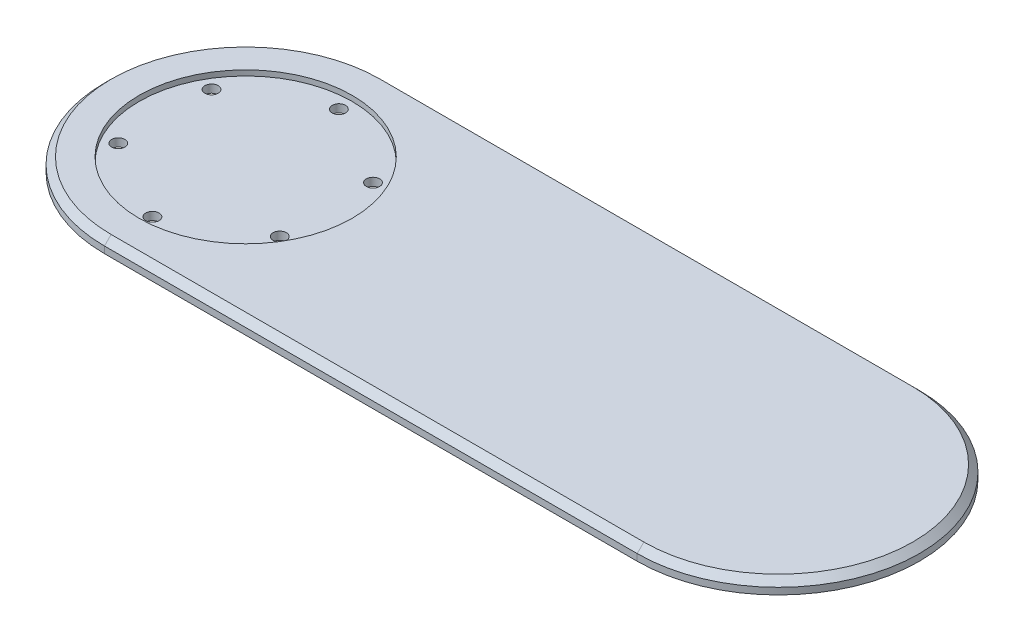
from build123d import *

# Parameters (mm, degrees)
SKETCH1_R           = 2.5
BOSS_EXTRUDE1_DEPTH = 5
SKETCH2_R           = 40
CUT_EXTRUDE1_DEPTH  = 2
CHAMFER1_SIZE       = 2.5


with BuildPart() as part:
    # Sketch1 → Boss-Extrude1 (new body)
    with BuildSketch(Plane(origin=(0, 0, 0), x_dir=(1, 0, 0), z_dir=(0, 1, 0))):
        with BuildLine():
            Line((-100, -53), (100, -53))
            ThreePointArc((100, -53), (153, 0), (100, 53))
            Line((100, 53), (-100, 53))
            ThreePointArc((-100, 53), (-153, 0), (-100, -53))
        make_face()
        with Locations((-100, -35)):
            Circle(SKETCH1_R, mode=Mode.SUBTRACT)
        with Locations((-100, 35)):
            Circle(SKETCH1_R, mode=Mode.SUBTRACT)
        with Locations((-69.689110868, 17.5)):
            Circle(SKETCH1_R, mode=Mode.SUBTRACT)
        with Locations((-69.689110868, -17.5)):
            Circle(SKETCH1_R, mode=Mode.SUBTRACT)
        with Locations((-130.310889132, 17.5)):
            Circle(SKETCH1_R, mode=Mode.SUBTRACT)
        with Locations((-130.310889132, -17.5)):
            Circle(SKETCH1_R, mode=Mode.SUBTRACT)
    extrude(amount=BOSS_EXTRUDE1_DEPTH)

    # Sketch2 → Cut-Extrude1 (cut)
    with BuildSketch(Plane(origin=(0, 5, 0), x_dir=(1, 0, 0), z_dir=(0, 1, 0))):
        with Locations((-100, 0)):
            Circle(SKETCH2_R)
    extrude(amount=-CUT_EXTRUDE1_DEPTH, mode=Mode.SUBTRACT)

    # Chamfer1
    chamfer1_edges = [part.edges().sort_by_distance(p)[0] for p in [
        (-153, 5, 0),
        (0, 5, 53),
        (153, 5, 0),
        (0, 5, -53),
    ]]
    chamfer(chamfer1_edges, length=CHAMFER1_SIZE)


solid = part.part
